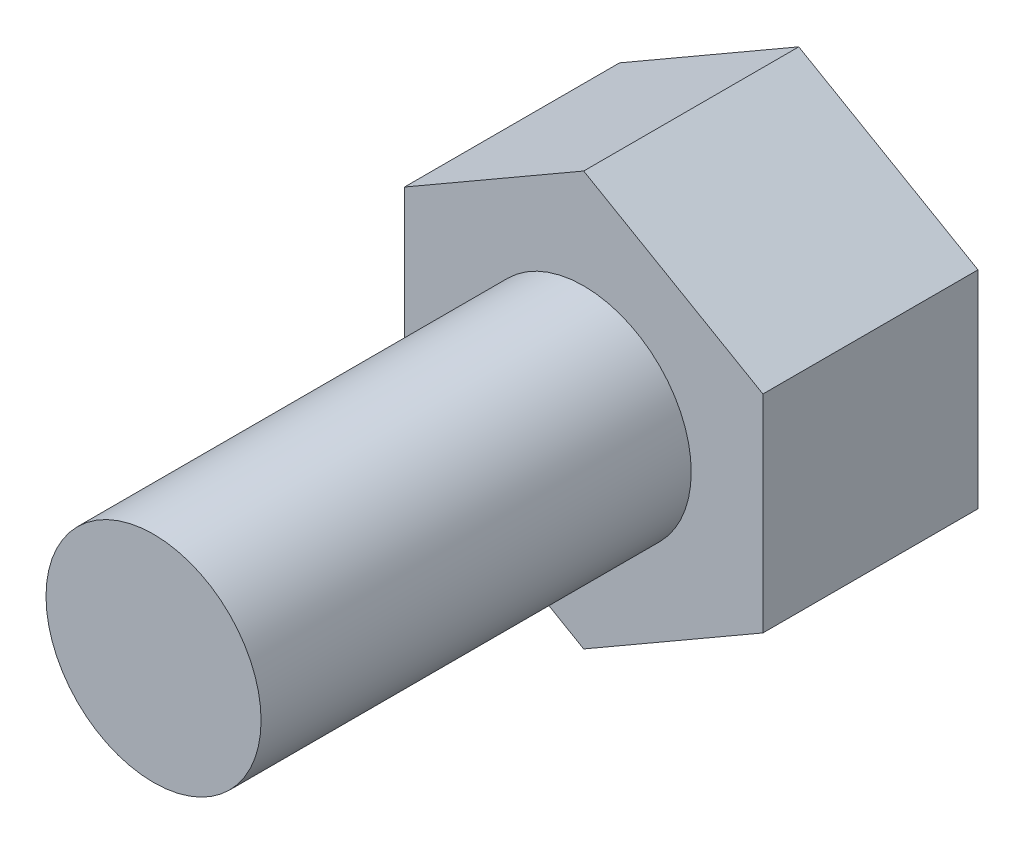
from build123d import *

# Parameters (mm, degrees)
SKETCH1_R           = 1.5
BOSS_EXTRUDE1_DEPTH = 6
BOSS_EXTRUDE2_DEPTH = 3


with BuildPart() as part:
    # Sketch1 → Boss-Extrude1 (new body)
    with BuildSketch(Plane.XY):
        with Locations((-63.49476159, 14.978708134)):
            Circle(SKETCH1_R)
    extrude(amount=BOSS_EXTRUDE1_DEPTH)

    # Sketch2 → Boss-Extrude2 (add)
    with BuildSketch(Plane(origin=(0, 0, 0), x_dir=(-1, 0, 0), z_dir=(0, 0, -1))):
        Polygon((63.49476159, 12.091956788), (65.99476159, 13.535332461), (65.99476159, 16.422083807), (63.49476159, 17.86545948), (60.99476159, 16.422083807), (60.99476159, 13.535332461), align=None)
    extrude(amount=BOSS_EXTRUDE2_DEPTH)


solid = part.part
